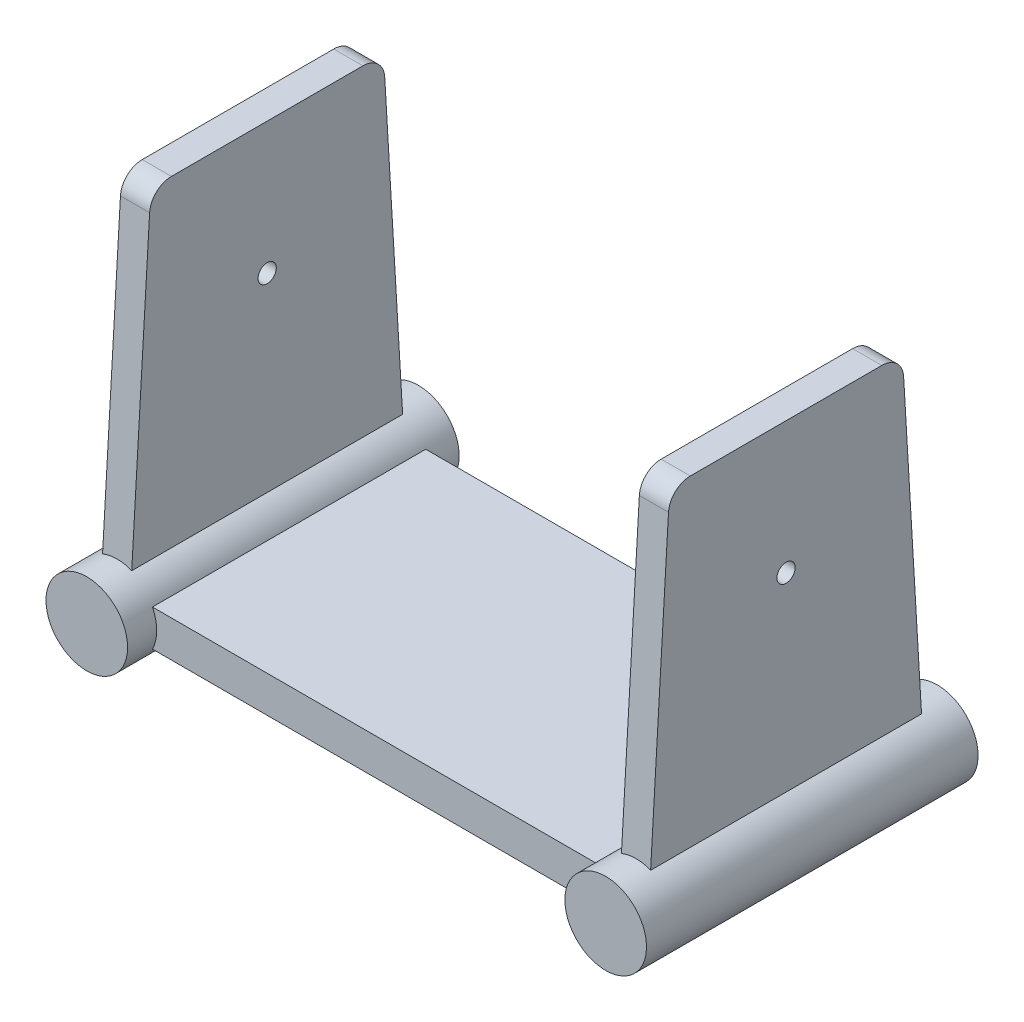
from build123d import *
from build123d.topology import SkipClean

# Parameters (mm, degrees)
SKETCH2_W           = 142.348460158
SKETCH2_H           = 74.966845352
BOSS_EXTRUDE1_DEPTH = 10
SKETCH3_2_R         = 11.189856227
BOSS_EXTRUDE3_DEPTH = 8
SKETCH6_R           = 2.5
BOSS_EXTRUDE5_DEPTH = 4
SKETCH3_R           = 11.189856227
BOSS_EXTRUDE2_DEPTH = 74.966845352
SKETCH4_R           = 11.189856227
BOSS_EXTRUDE4_DEPTH = 8
FILLET1_R           = 6
SKETCH8_R           = 4.167459473
BOSS_EXTRUDE6_DEPTH = 31
CUT_EXTRUDE1_DEPTH  = 31


with BuildPart() as part:
    # Sketch2 → Boss-Extrude1 (new body)
    with BuildSketch(Plane(origin=(0, 0, 0), x_dir=(1, 0, 0), z_dir=(0, 1, 0))):
        Rectangle(SKETCH2_W, SKETCH2_H)
    extrude(amount=BOSS_EXTRUDE1_DEPTH)

    # Sketch3_2 → Boss-Extrude3 (add)
    with BuildSketch(Plane.XY.offset(37.483422676)):
        with Locations(Location((-71.174230079, 5, 0), (0, 0, 333.459309643))):
            Circle(SKETCH3_2_R)
        with Locations(Location((71.174230079, 5, 0), (0, 0, 180))):
            Circle(SKETCH3_2_R)
    extrude(amount=BOSS_EXTRUDE3_DEPTH)

    # Sketch6 → Boss-Extrude5 (add, symmetric)
    with BuildSketch(Plane.ZY.offset(71.174230079)):
        Polygon((31.91575234, 103.68960792), (37.483422676, 10), (37.483422676, 0), (-37.483422676, 0), (-37.483422676, 10), (-31.91575234, 103.68960792), (0, 103.68960792), align=None)
        with Locations((0, 67.56317466)):
            Circle(SKETCH6_R, mode=Mode.SUBTRACT)
    boss_extrude5 = extrude(amount=BOSS_EXTRUDE5_DEPTH, both=True)

    # Sketch3 → Boss-Extrude2 (add)
    with BuildSketch(Plane.XY.offset(37.483422676)):
        with Locations(Location((-71.174230079, 5, 0), (0, 0, 333.459309643))):
            Circle(SKETCH3_R)
        with Locations(Location((71.174230079, 5, 0), (0, 0, 180))):
            Circle(SKETCH3_R)
    extrude(amount=-BOSS_EXTRUDE2_DEPTH)

    # Sketch4 → Boss-Extrude4 (add)
    with SkipClean():  # the faces are left unmerged after this step: merging them gives an invalid solid
        with BuildSketch(Plane(origin=(0, 0, -37.483422676), x_dir=(-1, 0, 0), z_dir=(0, 0, -1))):
            with Locations((-71.174230079, 5)):
                Circle(SKETCH4_R)
            with Locations((71.174230079, 5)):
                Circle(SKETCH4_R)
        extrude(amount=BOSS_EXTRUDE4_DEPTH)

    # Mirror1: Boss-Extrude5 across plane
    add(boss_extrude5.mirror(Plane(origin=(0, 0, 0), x_dir=(0, 0, 1), z_dir=(1, 0, 0))))

    # Fillet1
    fillet1_edges = [part.edges().sort_by_distance(p)[0] for p in [
        (71.174230079, 103.68960792, -31.91575234),
        (-71.174230079, 103.68960792, 31.91575234),
        (-71.174230079, 103.68960792, -31.91575234),
        (71.174230079, 103.68960792, 31.91575234),
    ]]
    fillet(fillet1_edges, radius=FILLET1_R)

    # Sketch8 → Boss-Extrude6 (add, symmetric)
    with BuildSketch(Plane(origin=(0, 0, 0), x_dir=(0, 0, -1), z_dir=(1, 0, 0))):
        with BuildLine():
            Line((-24.669316097, 0), (0, 0))
            Line((0, 0), (24.669316097, 0))
            ThreePointArc((24.669316097, 0), (0, -22.602874457), (-24.669316097, 0))
        make_face()
        with Locations((0, -11.517091371)):
            Circle(SKETCH8_R, mode=Mode.SUBTRACT)
    extrude(amount=BOSS_EXTRUDE6_DEPTH, both=True)

    # Sketch9 → Cut-Extrude1 (cut, symmetric)
    with BuildSketch(Plane.XY):
        Polygon((0, 0), (-23, 0), (-23, -24.601759038), (-2.110664843, -24.601759038), (23, -24.601759038), (23, 0), align=None)
    extrude(amount=CUT_EXTRUDE1_DEPTH, both=True, mode=Mode.SUBTRACT)


solid = part.part
